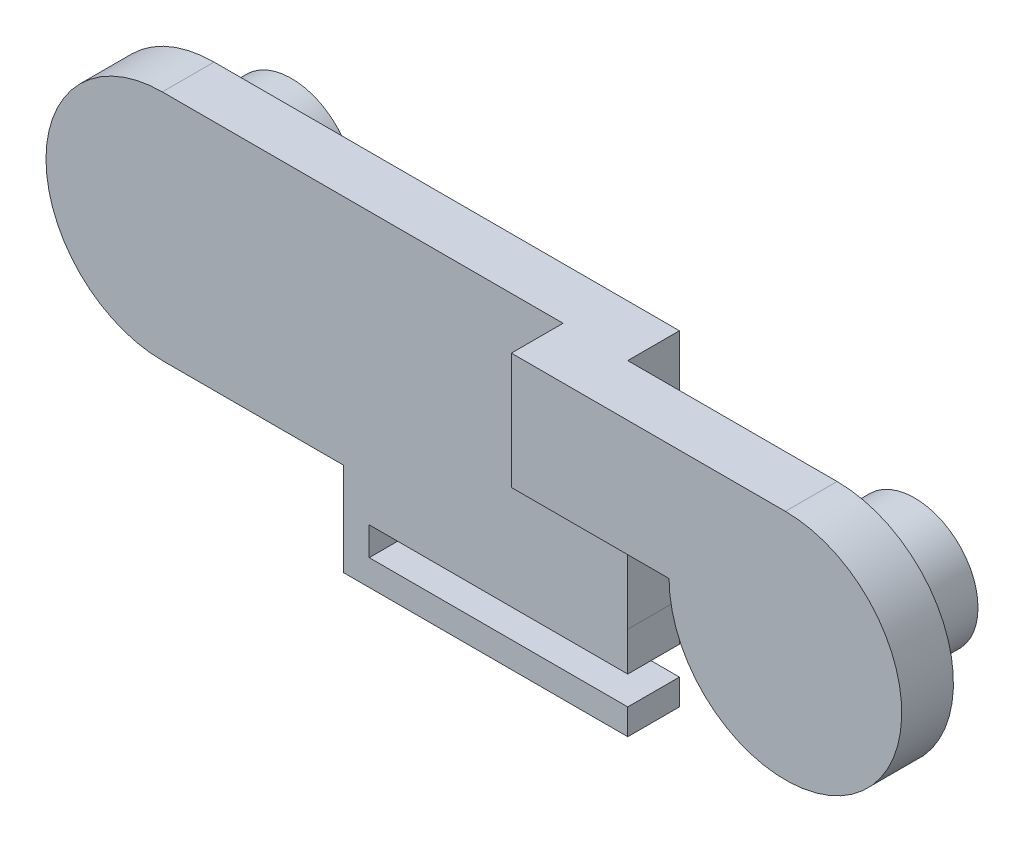
from build123d import *

# Parameters (mm, degrees)
SKETCH_1_R       = 2.45
EXTRUDE_1_DEPTH  = 2
SKETCH_1_3_R     = 2.45
EXTRUDE_2_DEPTH  = 2
SKETCH_3_W       = 2.5
SKETCH_3_H       = 4.5
EXTRUDE_3_DEPTH  = 2
EXTRUDE_START    = -5
SKETCH_5_R       = 2.45
EXTRUDE_4_DEPTH  = 5
EXTRUDE_8_DEPTH  = 2
SKETCH_13_W      = 2
SKETCH_13_H      = 3
EXTRUDE_12_DEPTH = 1
SKETCH_16_R      = 2.45
EXTRUDE_16_DEPTH = 5


with BuildPart() as part:
    # 草图1 → 凸台-拉伸1 (new body)
    with BuildSketch(Plane.XY):
        with BuildLine():
            Line((-52.360741066, -3.31033927), (-60.460741066, -3.31033927))
            Line((-60.460741066, -3.31033927), (-60.460741066, -7.81033927))
            Line((-60.460741066, -7.81033927), (-56.860741066, -7.81033927))
            ThreePointArc((-56.860741066, -7.81033927), (-49.178760551, -10.992319786), (-52.360741066, -3.31033927))
        make_face()
        with Locations((-52.360741066, -7.81033927)):
            Circle(SKETCH_1_R, mode=Mode.SUBTRACT)
    extrude(amount=EXTRUDE_1_DEPTH)



with BuildPart() as body_2:
    # 草图1<3> → 凸台-拉伸2 (new body)
    with BuildSketch(Plane.XY):
        with BuildLine():
            Line((-72.411189037, -12.31033927), (-70.458584645, -12.31033927))
            Line((-70.458584645, -12.31033927), (-70.458584645, -13.81033927))
            Line((-70.458584645, -13.81033927), (-65.458584645, -13.81033927))
            Line((-65.458584645, -13.81033927), (-60.458584645, -13.81033927))
            Line((-60.458584645, -13.81033927), (-60.460741066, -12.31033927))
            Line((-60.460741066, -12.31033927), (-60.460741066, -7.81033927))
            Line((-60.460741066, -7.81033927), (-60.460741066, -3.31033927))
            Line((-60.460741066, -3.31033927), (-78.460741066, -3.31033927))
            ThreePointArc((-78.460741066, -3.31033927), (-82.960741066, -7.81033927), (-78.460741066, -12.31033927))
            Line((-78.460741066, -12.31033927), (-72.411189037, -12.31033927))
        make_face()
        with Locations((-78.460741066, -7.81033927)):
            Circle(SKETCH_1_3_R, mode=Mode.SUBTRACT)
    extrude(amount=-EXTRUDE_2_DEPTH)


with BuildPart() as part_1:
    add(part.part)

    add(body_2.part)  # 凸台-拉伸3 merges body 2
    # 草图3 → 凸台-拉伸3 (add)
    with BuildSketch(Plane.XY):
        with Locations((-61.710741066, -5.56033927)):
            Rectangle(SKETCH_3_W, SKETCH_3_H)
    extrude(amount=EXTRUDE_3_DEPTH)

    # 草图5 → 凸台-拉伸4 (add)
    with BuildSketch(Plane.XY.offset(2).offset(EXTRUDE_START)):
        with Locations((-52.360741066, -7.81033927)):
            Circle(SKETCH_5_R)
    extrude(amount=EXTRUDE_4_DEPTH)

    # 草图10 → 凸台-拉伸8 (add)
    with BuildSketch(Plane(origin=(0, 0, -2), x_dir=(-1, 0, 0), z_dir=(0, 0, -1))):
        Polygon((70.458584645, -12.31033927), (71.458584645, -12.31033927), (71.458584645, -13.81033927), (71.458584645, -15.91033927), (70.458584645, -15.91033927), (60.458584645, -15.91033927), (60.458584645, -14.91033927), (70.458584645, -14.91033927), (70.458584645, -13.81033927), align=None)
    extrude(amount=-EXTRUDE_8_DEPTH)

    # 草图13 → 凸台-拉伸12 (add)
    with BuildSketch(Plane(origin=(0, 0, -2), x_dir=(-1, 0, 0), z_dir=(0, 0, -1))):
        with Locations((70.458584645, -14.41033927)):
            Rectangle(SKETCH_13_W, SKETCH_13_H)
    extrude(amount=EXTRUDE_12_DEPTH)

    # 草图16 → 凸台-拉伸16 (add)
    with BuildSketch(Plane.XY):
        with Locations((-78.460741066, -7.81033927)):
            Circle(SKETCH_16_R)
    extrude(amount=-EXTRUDE_16_DEPTH)


solid = part_1.part
